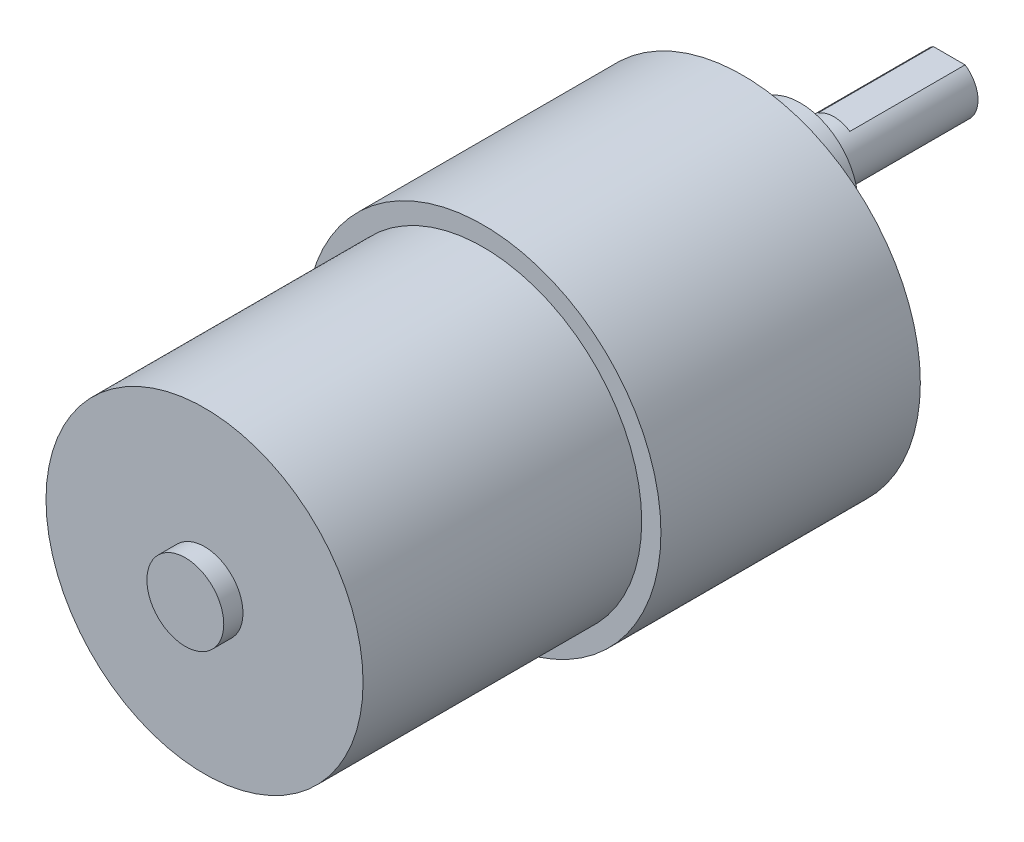
from build123d import *

# Parameters (mm, degrees)
SKETCH1_R               = 18.5
BOSS_EXTRUDE1_DEPTH     = 27
SKETCH2_R               = 16.5
BOSS_EXTRUDE2_DEPTH     = 29
SKETCH3_R               = 4
BOSS_EXTRUDE3_DEPTH     = 2
M3_TAPPED_HOLE1_D       = 2.5
M3_TAPPED_HOLE1_DEPTH   = 8.5
M3_TAPPED_HOLE1_TIP     = 0.751075774
SKETCH4_R               = 6
BOSS_EXTRUDE4_DEPTH     = 6
SKETCH7_R               = 3
BOSS_EXTRUDE5_DEPTH     = 15.5
CUT_EXTRUDE1_DEPTH      = 1
CUT_EXTRUDE1_DEPTH_BACK = 12


with BuildPart() as part:
    # Sketch1 → Boss-Extrude1 (new body)
    with BuildSketch(Plane.XY):
        Circle(SKETCH1_R)
    extrude(amount=BOSS_EXTRUDE1_DEPTH)

    # Sketch2 → Boss-Extrude2 (add)
    with BuildSketch(Plane.XY.offset(27)):
        Circle(SKETCH2_R)
    extrude(amount=BOSS_EXTRUDE2_DEPTH)

    # Sketch3 → Boss-Extrude3 (add)
    with BuildSketch(Plane.XY.offset(56)):
        Circle(SKETCH3_R)
    extrude(amount=BOSS_EXTRUDE3_DEPTH)

    # M3 Tapped Hole1
    with Locations(Plane(origin=(15.5, -0.178765265, 0), x_dir=(-1, 0, 0), z_dir=(0, 0, -1))):
        with Locations((0, 0), (7.59518474, 13.512776391), (23.09518474, 13.691541656), (31, 0.35753053), (23.40481526, -13.155245861), (7.90481526, -13.334011126)):
            Hole(M3_TAPPED_HOLE1_D / 2, depth=M3_TAPPED_HOLE1_DEPTH)
            with Locations((0, 0, -(M3_TAPPED_HOLE1_DEPTH + M3_TAPPED_HOLE1_TIP / 2))):  # 118° drill point
                Cone(0, M3_TAPPED_HOLE1_D / 2, M3_TAPPED_HOLE1_TIP, mode=Mode.SUBTRACT)

    # Sketch4 → Boss-Extrude4 (add)
    with BuildSketch(Plane(origin=(0, 0, 0), x_dir=(-1, 0, 0), z_dir=(0, 0, -1))):
        with Locations((0, 7.000465539)):
            Circle(SKETCH4_R)
    extrude(amount=BOSS_EXTRUDE4_DEPTH)

    # Sketch7 → Boss-Extrude5 (add)
    with BuildSketch(Plane(origin=(0, 0, -6), x_dir=(-1, 0, 0), z_dir=(0, 0, -1))):
        with Locations((0, 7.000465539)):
            Circle(SKETCH7_R)
    extrude(amount=BOSS_EXTRUDE5_DEPTH)

    # Sketch8 → Cut-Extrude1 (cut, two sides)
    with BuildSketch(Plane(origin=(0, 0, -21.5), x_dir=(-1, 0, 0), z_dir=(0, 0, -1))) as cut_extrude1_sk:
        Polygon((-80.662185592, 9.500465539), (-1.658312395, 9.500465539), (1.658312395, 9.500465539), (80.662185592, 9.500465539), (80.662185592, 167.508211933), (-80.662185592, 167.508211933), align=None)
    extrude(amount=CUT_EXTRUDE1_DEPTH, mode=Mode.SUBTRACT)
    extrude(cut_extrude1_sk.sketch, amount=-CUT_EXTRUDE1_DEPTH_BACK, mode=Mode.SUBTRACT)


solid = part.part
